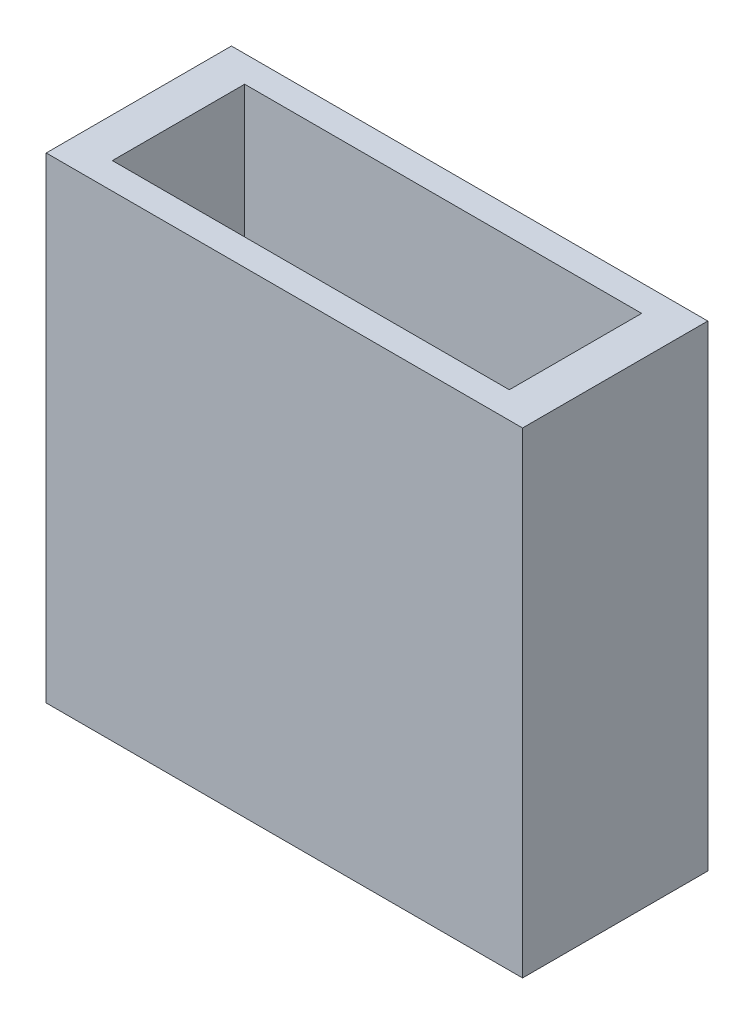
from build123d import *

# Parameters (mm, degrees)
SKETCH1_W               = 45.72
SKETCH1_H               = 17.78
BOSS_EXTRUDE1_DEPTH     = 45.72
SKETCH2_W               = 38.1
SKETCH2_H               = 12.7
CUT_EXTRUDE1_DEPTH      = 41.91
SKETCH6_R               = 3.048
CUT_EXTRUDE2_DEPTH      = 9.328339826
CUT_EXTRUDE2_DEPTH_BACK = 15.24


with BuildPart() as part:
    # Sketch1 → Boss-Extrude1 (new body)
    with BuildSketch(Plane(origin=(0, 0, 0), x_dir=(1, 0, 0), z_dir=(0, 1, 0))):
        with Locations((22.86, 8.89)):
            Rectangle(SKETCH1_W, SKETCH1_H)
    extrude(amount=BOSS_EXTRUDE1_DEPTH)

    # Sketch2 → Cut-Extrude1 (cut)
    with BuildSketch(Plane(origin=(0, 45.72, 0), x_dir=(1, 0, 0), z_dir=(0, 1, 0))):
        with Locations((22.86, 8.89)):
            Rectangle(SKETCH2_W, SKETCH2_H)
    extrude(amount=-CUT_EXTRUDE1_DEPTH, mode=Mode.SUBTRACT)

    # Sketch6 → Cut-Extrude2 (cut, two sides)
    with BuildSketch(Plane(origin=(0, 0, 0), x_dir=(0.974501657, 0.176548089, -0.138482102), z_dir=(0.182159664, -0.982845594, 0.028851256))) as cut_extrude2_sk:
        with Locations((23.128298386, -5.852866773)):
            Circle(SKETCH6_R)
        with Locations((16.079712461, -6.800485078)):
            Circle(SKETCH6_R)
        with Locations((30.176884312, -4.905248468)):
            Circle(SKETCH6_R)
    extrude(amount=CUT_EXTRUDE2_DEPTH, mode=Mode.SUBTRACT)
    extrude(cut_extrude2_sk.sketch, amount=-CUT_EXTRUDE2_DEPTH_BACK, mode=Mode.SUBTRACT)


solid = part.part
